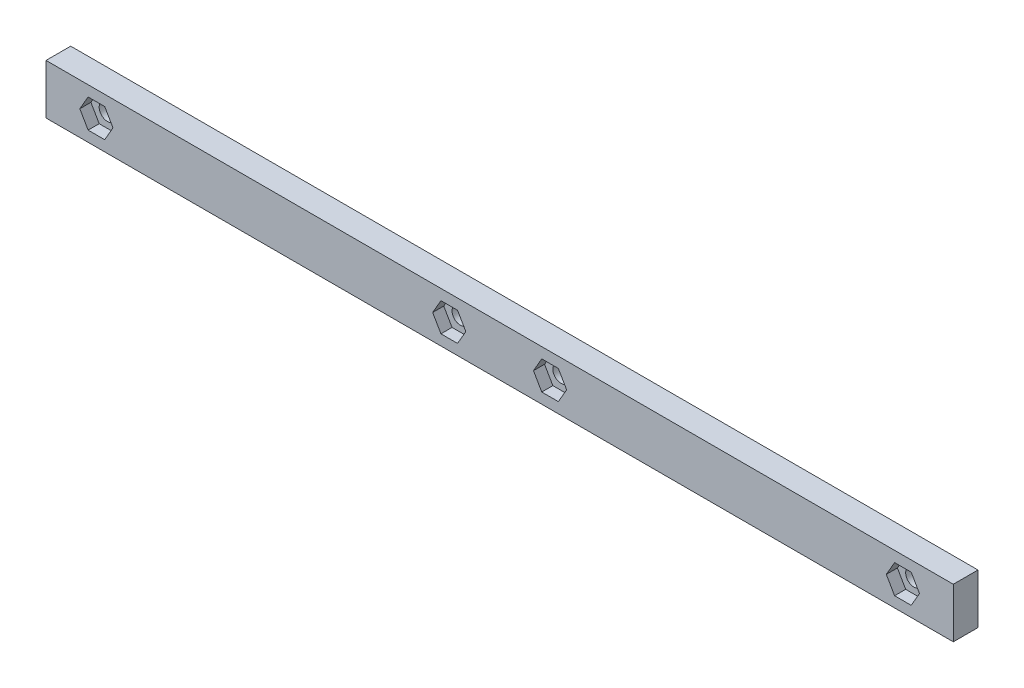
from build123d import *

# Parameters (mm, degrees)
SKETCH1_W           = 180
SKETCH1_H           = 9.9
BOSS_EXTRUDE1_DEPTH = 4.9
SKETCH2_R           = 1.65
CUT_EXTRUDE1_DEPTH  = 5.9
CUT_EXTRUDE2_DEPTH  = 2.2


with BuildPart() as part:
    # Sketch1 → Boss-Extrude1 (new body)
    with BuildSketch(Plane.XY):
        with Locations((-56.357347179, 33.440788785)):
            Rectangle(SKETCH1_W, SKETCH1_H)
    extrude(amount=-BOSS_EXTRUDE1_DEPTH)

    # Sketch2 → Cut-Extrude1 (cut, through all)
    with BuildSketch(Plane.XY):
        with Locations((-136.357347179, 33.440788785)):
            Circle(SKETCH2_R)
        with Locations((-66.357347179, 33.440788785)):
            Circle(SKETCH2_R)
        with Locations((-46.357347179, 33.440788785)):
            Circle(SKETCH2_R)
        with Locations((23.642652821, 33.440788785)):
            Circle(SKETCH2_R)
    extrude(amount=-CUT_EXTRUDE1_DEPTH, mode=Mode.SUBTRACT)

    # Sketch3 → Cut-Extrude2 (cut)
    with BuildSketch(Plane.XY):
        Polygon((-134.711898912, 30.590788785), (-133.066450645, 33.440788785), (-134.711898912, 36.290788785), (-138.002795446, 36.290788785), (-139.648243713, 33.440788785), (-138.002795446, 30.590788785), align=None)
        Polygon((-64.711898912, 30.590788785), (-63.066450645, 33.440788785), (-64.711898912, 36.290788785), (-68.002795446, 36.290788785), (-69.648243713, 33.440788785), (-68.002795446, 30.590788785), align=None)
        Polygon((-44.711898912, 30.590788785), (-43.066450645, 33.440788785), (-44.711898912, 36.290788785), (-48.002795446, 36.290788785), (-49.648243713, 33.440788785), (-48.002795446, 30.590788785), align=None)
        Polygon((25.288101088, 30.590788785), (26.933549355, 33.440788785), (25.288101088, 36.290788785), (21.997204554, 36.290788785), (20.351756287, 33.440788785), (21.997204554, 30.590788785), align=None)
    extrude(amount=-CUT_EXTRUDE2_DEPTH, mode=Mode.SUBTRACT)


solid = part.part
